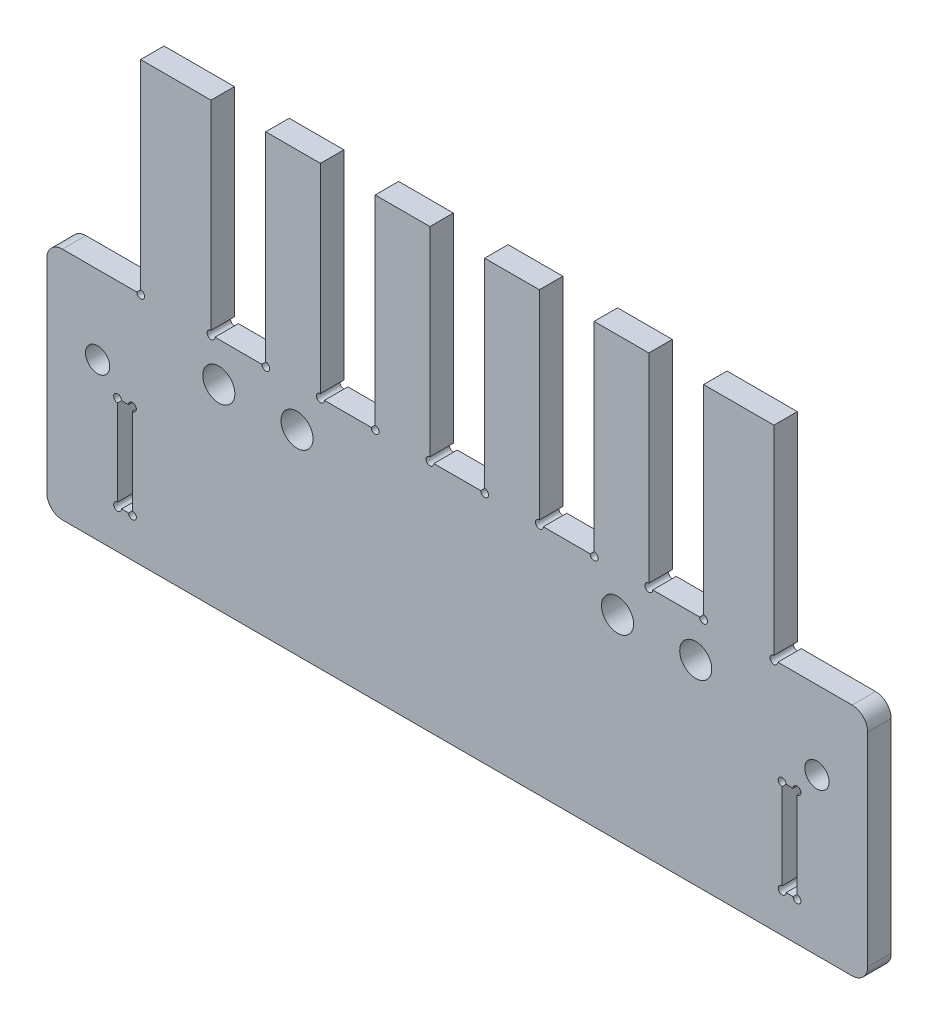
from build123d import *

# Parameters (mm, degrees)
SKETCH_1_W          = 105
SKETCH_1_H          = 53.5
EXTRUDE_1_DEPTH     = 3
SKETCH_2_R          = 1.55
SKETCH_2_W          = 2
SKETCH_2_H          = 12
CUT_EXTRUDE_1_DEPTH = 5
SKETCH_3_W          = 7
SKETCH_3_H          = 26
SKETCH_3_W_2        = 12
CUT_EXTRUDE_2_DEPTH = 4
SKETCH_8_W          = 105
SKETCH_8_H          = 2.5
EXTRUDE_2_DEPTH     = 3
FILLET_1_R          = 2
SKETCH_7_R          = 0.5
CUT_EXTRUDE_6_DEPTH = 10
SKETCH_10_W         = 0.05
SKETCH_10_H         = 12
EXTRUDE_3_DEPTH     = 3
SKETCH_11_R         = 0.5
CUT_EXTRUDE_7_DEPTH = 10
SKETCH_12_R         = 2.05
CUT_EXTRUDE_8_DEPTH = 10


with BuildPart() as part:
    # 草图1 → 凸台-拉伸1 (new body)
    with BuildSketch(Plane.XY):
        Rectangle(SKETCH_1_W, SKETCH_1_H)
    extrude(amount=EXTRUDE_1_DEPTH)

    # 草图2 → 切除-拉伸1 (cut)
    with BuildSketch(Plane(origin=(0, 0, 0), x_dir=(-1, 0, 0), z_dir=(0, 0, -1))):
        with Locations((46, -9.25)):
            Circle(SKETCH_2_R)
        with Locations((-46, -9.25)):
            Circle(SKETCH_2_R)
        with Locations((42.5, -18.25)):
            Rectangle(SKETCH_2_W, SKETCH_2_H)
        with Locations((-42.5, -18.25)):
            Rectangle(SKETCH_2_W, SKETCH_2_H)
    extrude(amount=-CUT_EXTRUDE_1_DEPTH, mode=Mode.SUBTRACT)

    # 草图3 → 切除-拉伸2 (cut, through all)
    with BuildSketch(Plane(origin=(0, 0, 0), x_dir=(-1, 0, 0), z_dir=(0, 0, -1))):
        with Locations((-28, 13.75)):
            Rectangle(SKETCH_3_W, SKETCH_3_H)
        with Locations((-14, 13.75)):
            Rectangle(SKETCH_3_W, SKETCH_3_H)
        with Locations((46.5, 13.75)):
            Rectangle(SKETCH_3_W_2, SKETCH_3_H)
        with Locations((28, 13.75)):
            Rectangle(SKETCH_3_W, SKETCH_3_H)
        with Locations((0, 13.75)):
            Rectangle(SKETCH_3_W, SKETCH_3_H)
        with Locations((-46.5, 13.75)):
            Rectangle(SKETCH_3_W_2, SKETCH_3_H)
        with Locations((14, 13.75)):
            Rectangle(SKETCH_3_W, SKETCH_3_H)
    extrude(amount=-CUT_EXTRUDE_2_DEPTH, mode=Mode.SUBTRACT)

    # 草图8 → 凸台-拉伸2 (add)
    with BuildSketch(Plane(origin=(0, 0, 0), x_dir=(-1, 0, 0), z_dir=(0, 0, -1))):
        with Locations((0, -28)):
            Rectangle(SKETCH_8_W, SKETCH_8_H)
    extrude(amount=-EXTRUDE_2_DEPTH)

    # 圆角1
    fillet_1_edges = [part.edges().sort_by_distance(p)[0] for p in [
        (-52.5, 0.75, 1.5),
        (52.5, 0.75, 1.5),
        (-52.5, -29.25, 1.5),
        (52.5, -29.25, 1.5),
    ]]
    fillet(fillet_1_edges, radius=FILLET_1_R)

    # 草图7 → 切除-拉伸6 (cut)
    with BuildSketch(Plane(origin=(0, 0, 0), x_dir=(-1, 0, 0), z_dir=(0, 0, -1))):
        with Locations((-40.5, 0.75)):
            Circle(SKETCH_7_R)
        with Locations((-31.5, 0.75)):
            Circle(SKETCH_7_R)
        with Locations((-24.5, 0.75)):
            Circle(SKETCH_7_R)
        with Locations((-17.5, 0.75)):
            Circle(SKETCH_7_R)
        with Locations((-10.5, 0.75)):
            Circle(SKETCH_7_R)
        with Locations((24.5, 0.75)):
            Circle(SKETCH_7_R)
        with Locations((31.5, 0.75)):
            Circle(SKETCH_7_R)
        with Locations((40.5, 0.75)):
            Circle(SKETCH_7_R)
        with Locations((-3.5, 0.75)):
            Circle(SKETCH_7_R)
        with Locations((3.5, 0.75)):
            Circle(SKETCH_7_R)
        with Locations((10.5, 0.75)):
            Circle(SKETCH_7_R)
        with Locations((17.5, 0.75)):
            Circle(SKETCH_7_R)
    extrude(amount=-CUT_EXTRUDE_6_DEPTH, mode=Mode.SUBTRACT)

    # 草图10 → 凸台-拉伸3 (add)
    with BuildSketch(Plane(origin=(0, 0, 0), x_dir=(-1, 0, 0), z_dir=(0, 0, -1))):
        with Locations((43.475, -18.25)):
            Rectangle(SKETCH_10_W, SKETCH_10_H)
        with Locations((41.525, -18.25)):
            Rectangle(SKETCH_10_W, SKETCH_10_H)
        with Locations((-41.525, -18.25)):
            Rectangle(SKETCH_10_W, SKETCH_10_H)
        with Locations((-43.475, -18.25)):
            Rectangle(SKETCH_10_W, SKETCH_10_H)
    extrude(amount=-EXTRUDE_3_DEPTH)

    # 草图11 → 切除-拉伸7 (cut)
    with BuildSketch(Plane(origin=(0, 0, 0), x_dir=(-1, 0, 0), z_dir=(0, 0, -1))):
        with Locations((43.45, -24.25)):
            Circle(SKETCH_11_R)
        with Locations((41.55, -24.25)):
            Circle(SKETCH_11_R)
        with Locations((43.45, -12.25)):
            Circle(SKETCH_11_R)
        with Locations((41.55, -12.25)):
            Circle(SKETCH_11_R)
        with Locations((-41.55, -24.25)):
            Circle(SKETCH_11_R)
        with Locations((-43.45, -24.25)):
            Circle(SKETCH_11_R)
        with Locations((-43.45, -12.25)):
            Circle(SKETCH_11_R)
        with Locations((-41.55, -12.25)):
            Circle(SKETCH_11_R)
    extrude(amount=-CUT_EXTRUDE_7_DEPTH, mode=Mode.SUBTRACT)

    # 草图12 → 切除-拉伸8 (cut)
    with BuildSketch(Plane(origin=(0, 0, 0), x_dir=(-1, 0, 0), z_dir=(0, 0, -1))):
        with Locations((-30.5, -4.25)):
            Circle(SKETCH_12_R)
        with Locations((-20.5, -4.25)):
            Circle(SKETCH_12_R)
        with Locations((20.5, -4.25)):
            Circle(SKETCH_12_R)
        with Locations((30.5, -4.25)):
            Circle(SKETCH_12_R)
    extrude(amount=-CUT_EXTRUDE_8_DEPTH, mode=Mode.SUBTRACT)


solid = part.part
